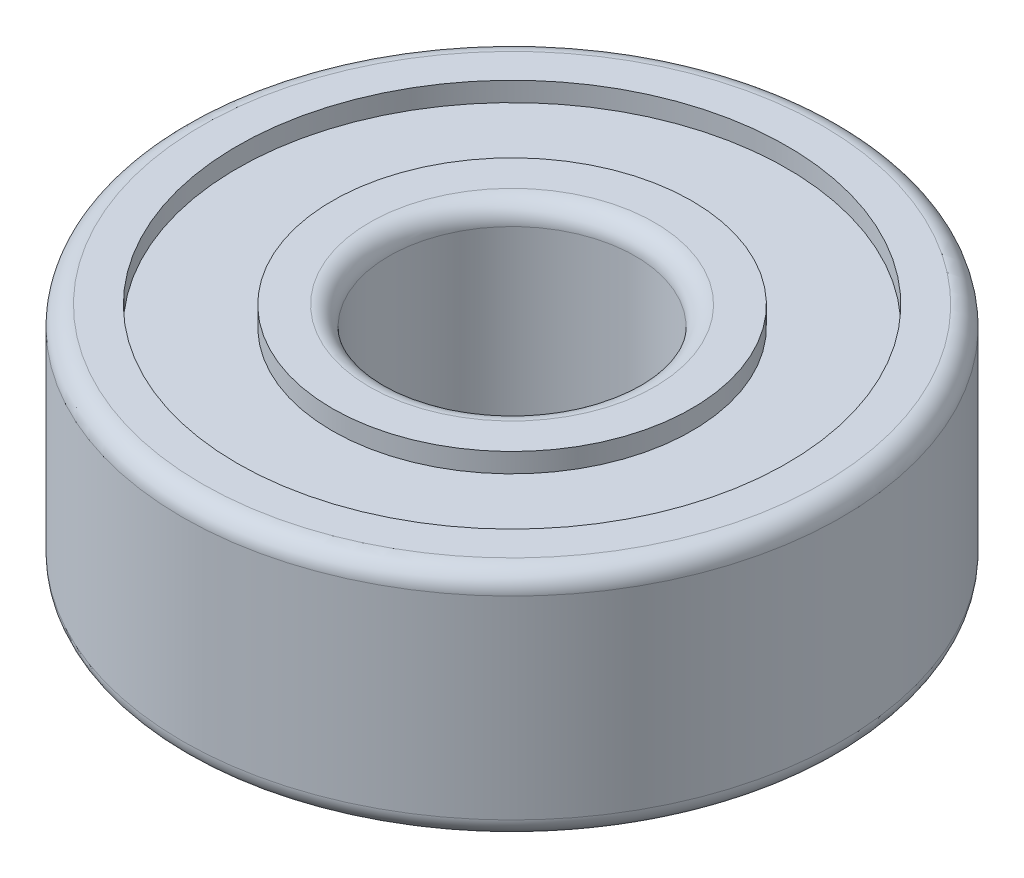
from build123d import *

# Parameters (mm, degrees)
SKETCH1_R           = 17
SKETCH1_R_2         = 6.35
BOSS_EXTRUDE1_DEPTH = 12
FILLET1_R           = 1
SKETCH2_R           = 14.179085796
SKETCH2_R_2         = 9.276544236
CUT_EXTRUDE1_DEPTH  = 1
SKETCH3_R           = 14.472019466
SKETCH3_R_2         = 9.262101897
CUT_EXTRUDE2_DEPTH  = 1


with BuildPart() as part:
    # Sketch1 → Boss-Extrude1 (new body)
    with BuildSketch(Plane(origin=(0, 0, 0), x_dir=(1, 0, 0), z_dir=(0, 1, 0))):
        Circle(SKETCH1_R)
        Circle(SKETCH1_R_2, mode=Mode.SUBTRACT)
    extrude(amount=BOSS_EXTRUDE1_DEPTH)

    # Fillet1
    fillet1_edges = [part.edges().sort_by_distance(p)[0] for p in [
        (-17, 0, 0),
        (-17, 12, 0),
        (-6.35, 0, 0),
        (-6.35, 12, 0),
    ]]
    fillet(fillet1_edges, radius=FILLET1_R)

    # Sketch2 → Cut-Extrude1 (cut)
    with BuildSketch(Plane(origin=(0, 12, 0), x_dir=(1, 0, 0), z_dir=(0, 1, 0))):
        Circle(SKETCH2_R)
        Circle(SKETCH2_R_2, mode=Mode.SUBTRACT)
    extrude(amount=-CUT_EXTRUDE1_DEPTH, mode=Mode.SUBTRACT)

    # Sketch3 → Cut-Extrude2 (cut)
    with BuildSketch(Plane.XZ):
        Circle(SKETCH3_R)
        Circle(SKETCH3_R_2, mode=Mode.SUBTRACT)
    extrude(amount=-CUT_EXTRUDE2_DEPTH, mode=Mode.SUBTRACT)


solid = part.part
